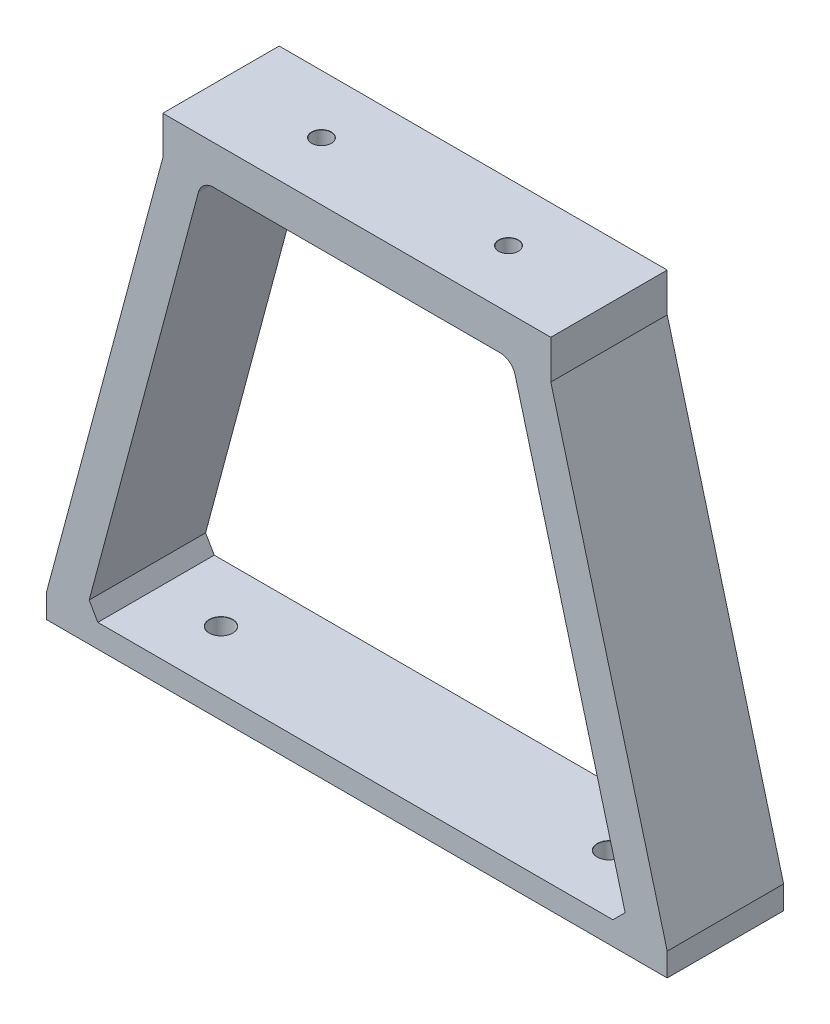
from build123d import *
from OCP.BRepFilletAPI import BRepFilletAPI_MakeChamfer

# Parameters (mm, degrees)
SKETCH1_W                       = 50
SKETCH1_H                       = 15
BOSS_EXTRUDE1_DEPTH             = 5
BOSS_EXTRUDE2_DEPTH             = 15
FILLET1_R                       = 2
SKETCH3_W                       = 80
SKETCH3_H                       = 15
BOSS_EXTRUDE3_DEPTH             = 3
CHAMFER1_SIZE                   = 2
CHAMFER1_SIZE2                  = 1.633074145
F_3_0MM_DOWEL_HOLE1_D           = 3
F_3_0MM_DOWEL_HOLE1_DEPTH       = 20
F_3_0MM_DOWEL_HOLE1_CSINK_D     = 3.05
F_3_0MM_DOWEL_HOLE1_CSINK_ANGLE = 90
F_3_0MM_DOWEL_HOLE1_TIP         = 0.901290929
F_2_5MM_DOWEL_HOLE1_D           = 2.5
F_2_5MM_DOWEL_HOLE1_DEPTH       = 20
F_2_5MM_DOWEL_HOLE1_CSINK_D     = 2.55
F_2_5MM_DOWEL_HOLE1_CSINK_ANGLE = 90
F_2_5MM_DOWEL_HOLE1_TIP         = 0.751075774


with BuildPart() as part:
    # Sketch1 → Boss-Extrude1 (new body)
    with BuildSketch(Plane(origin=(0, 0, 0), x_dir=(1, 0, 0), z_dir=(0, 1, 0))):
        Rectangle(SKETCH1_W, SKETCH1_H)
    extrude(amount=BOSS_EXTRUDE1_DEPTH)

    # Sketch2 → Boss-Extrude2 (add)
    with BuildSketch(Plane.XY.offset(7.5)):
        Polygon((25, 0), (40, -56), (35, -56), (20, 0), align=None)
        Polygon((-25, 0), (-40, -56), (-35, -56), (-20, 0), align=None)
    extrude(amount=-BOSS_EXTRUDE2_DEPTH)

    # Fillet1
    fillet1_edges = [part.edges().sort_by_distance(p)[0] for p in [
        (20, 0, 0),
        (-20, 0, 0),
    ]]
    fillet(fillet1_edges, radius=FILLET1_R)

    # Sketch3 → Boss-Extrude3 (add)
    with BuildSketch(Plane.XZ.offset(56)):
        Rectangle(SKETCH3_W, SKETCH3_H)
    extrude(amount=BOSS_EXTRUDE3_DEPTH)

    # Chamfer1: one chamfer whose edges measure the first distance from different faces: ONE call of the kernel's chamfer builder (chamfer() names one face for all edges)
    chamfer1_edges_1 = [part.edges().sort_by_distance(p)[0] for p in [
        (35, -56, 0),
    ]]
    chamfer1_side_1 = [part.faces().sort_by_distance(p)[0] for p in [
        (0, -56, 0),
    ]]
    chamfer1_edges_2 = [part.edges().sort_by_distance(p)[0] for p in [
        (-35, -56, 0),
    ]]
    chamfer1_side_2 = [part.faces().sort_by_distance(p)[0] for p in [
        (-27.698552834, -28.741263915, 0),
    ]]
    chamfer1 = BRepFilletAPI_MakeChamfer(part.part.solid().wrapped)
    for e in chamfer1_edges_1:
        chamfer1.Add(CHAMFER1_SIZE, CHAMFER1_SIZE2, e.wrapped, chamfer1_side_1[0].wrapped)  # the first distance lies on this face
    for e in chamfer1_edges_2:
        chamfer1.Add(CHAMFER1_SIZE, CHAMFER1_SIZE2, e.wrapped, chamfer1_side_2[0].wrapped)  # the first distance lies on this face
    add(Compound.cast(chamfer1.Shape()), mode=Mode.REPLACE)

    # Ø3.0mm Dowel Hole1
    with Locations(Plane(origin=(0, -56, 0), x_dir=(1, 0, 0), z_dir=(0, 1, 0))):
        with Locations((-25, 0), (25, 0)):
            CounterSinkHole(F_3_0MM_DOWEL_HOLE1_D / 2, F_3_0MM_DOWEL_HOLE1_CSINK_D / 2, depth=F_3_0MM_DOWEL_HOLE1_DEPTH, counter_sink_angle=F_3_0MM_DOWEL_HOLE1_CSINK_ANGLE)
            with Locations((0, 0, -(F_3_0MM_DOWEL_HOLE1_DEPTH + F_3_0MM_DOWEL_HOLE1_TIP / 2))):  # 118° drill point
                Cone(0, F_3_0MM_DOWEL_HOLE1_D / 2, F_3_0MM_DOWEL_HOLE1_TIP, mode=Mode.SUBTRACT)

    # Ø2.5mm Dowel Hole1
    with Locations(Plane(origin=(0, 5, 0), x_dir=(1, 0, 0), z_dir=(0, 1, 0))):
        with Locations((-12.05, 0), (12.05, 0)):
            CounterSinkHole(F_2_5MM_DOWEL_HOLE1_D / 2, F_2_5MM_DOWEL_HOLE1_CSINK_D / 2, depth=F_2_5MM_DOWEL_HOLE1_DEPTH, counter_sink_angle=F_2_5MM_DOWEL_HOLE1_CSINK_ANGLE)
            with Locations((0, 0, -(F_2_5MM_DOWEL_HOLE1_DEPTH + F_2_5MM_DOWEL_HOLE1_TIP / 2))):  # 118° drill point
                Cone(0, F_2_5MM_DOWEL_HOLE1_D / 2, F_2_5MM_DOWEL_HOLE1_TIP, mode=Mode.SUBTRACT)


solid = part.part
